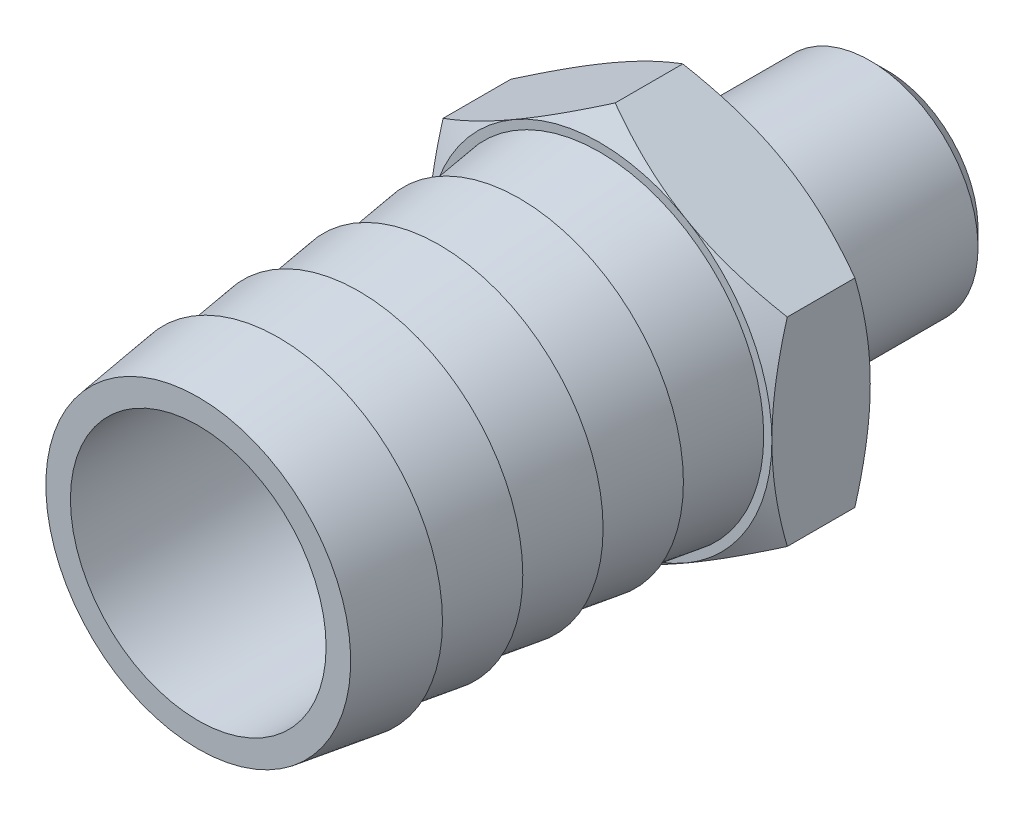
from build123d import *

# Parameters (mm, degrees)
LPATTERN1_COUNT     = 5
LPATTERN1_PITCH     = 4.9
BOSS_EXTRUDE1_START = -9.5
BOSS_EXTRUDE1_DEPTH = 6
SKETCH5_OUTSIDE_W   = 136.756
SKETCH5_OUTSIDE_H   = 140.004
SKETCH5_OUTSIDE_R   = 10.5
CUT_EXTRUDE1_DEPTH  = 30.283100929
CUT_EXTRUDE1_DRAFT  = -60
SKETCH6_OUTSIDE_W   = 154.69
SKETCH6_OUTSIDE_H   = 157.938
SKETCH6_OUTSIDE_R   = 10.5
CUT_EXTRUDE2_DEPTH  = 35.46012188
CUT_EXTRUDE2_DRAFT  = -60
SKETCH12_R          = 1.123521783


with BuildPart() as part:
    # Sketch2 → Revolve2 (revolve)
    with BuildSketch(Plane(origin=(0, 0, 0), x_dir=(0, 0, -1), z_dir=(1, 0, 0)), mode=Mode.PRIVATE) as revolve2_sk:
        Polygon((-21, 9.3), (-16.1, 10), (-16.1, 0), (-21, 0), align=None)
    revolve(revolve2_sk.sketch.rotate(Axis((0, 0, 21), (0, 0, -1)), 180), axis=Axis((0, 0, 21), (0, 0, -1)))


with BuildPart() as lpattern1_1:
    # LPattern1: pattern copy
    add(part.part.moved(Location(Vector(0, 0, -1) * (1 * LPATTERN1_PITCH))))


with BuildPart() as lpattern1_2:
    # LPattern1: pattern copy
    add(part.part.moved(Location(Vector(0, 0, -1) * (2 * LPATTERN1_PITCH))))


with BuildPart() as lpattern1_3:
    # LPattern1: pattern copy
    add(part.part.moved(Location(Vector(0, 0, -1) * (3 * LPATTERN1_PITCH))))


with BuildPart() as lpattern1_4:
    # LPattern1: pattern copy
    add(part.part.moved(Location(Vector(0, 0, -1) * (4 * LPATTERN1_PITCH))))


with BuildPart() as body_6:
    # Sketch3 → Boss-Extrude1 (new body)
    with BuildSketch(Plane.XY.offset(BOSS_EXTRUDE1_START)):
        Polygon((0, 12.124355653), (-10.5, 6.062177826), (-10.5, -6.062177826), (0, -12.124355653), (10.5, -6.062177826), (10.5, 6.062177826), align=None)
    extrude(amount=BOSS_EXTRUDE1_DEPTH)


with BuildPart() as cut_extrude1_tool:
    # Sketch5 outside → Cut-Extrude1 (with draft: the straight prism first)
    with BuildSketch(Plane.XY.offset(-3.5)):
        Rectangle(SKETCH5_OUTSIDE_W, SKETCH5_OUTSIDE_H)
        Circle(SKETCH5_OUTSIDE_R, mode=Mode.SUBTRACT)
    extrude(amount=-CUT_EXTRUDE1_DEPTH)
    # Cut-Extrude1: the draft: its side faces are tilted about the plane it starts from
    cut_extrude1_sides = [cut_extrude1_tool.faces().sort_by_distance(p)[0] for p in [
        (0, -70.002, -18.641550464),
        (68.378, 0, -18.641550464),
        (0, 70.002, -18.641550464),
        (-68.378, 0, -18.641550464),
        (-10.5, 0, -18.641550464),
    ]]
    draft(cut_extrude1_sides, Plane.XY.offset(-3.5), CUT_EXTRUDE1_DRAFT)


with BuildPart() as body_6_1:
    add(body_6.part)

    # Cut-Extrude1: cut by cut_extrude1_tool
    add(cut_extrude1_tool.part, mode=Mode.SUBTRACT)


with BuildPart() as cut_extrude2_tool:
    # Sketch6 outside → Cut-Extrude2 (with draft: the straight prism first)
    with BuildSketch(Plane(origin=(0, 0, -9.5), x_dir=(-1, 0, 0), z_dir=(0, 0, -1))):
        Rectangle(SKETCH6_OUTSIDE_W, SKETCH6_OUTSIDE_H)
        Circle(SKETCH6_OUTSIDE_R, mode=Mode.SUBTRACT)
    extrude(amount=-CUT_EXTRUDE2_DEPTH)
    # Cut-Extrude2: the draft: its side faces are tilted about the plane it starts from
    cut_extrude2_sides = [cut_extrude2_tool.faces().sort_by_distance(p)[0] for p in [
        (0, -78.969, 8.23006094),
        (-77.345, 0, 8.23006094),
        (0, 78.969, 8.23006094),
        (77.345, 0, 8.23006094),
        (10.5, 0, 8.23006094),
    ]]
    draft(cut_extrude2_sides, Plane(origin=(0, 0, -9.5), x_dir=(-1, 0, 0), z_dir=(0, 0, -1)), CUT_EXTRUDE2_DRAFT)


with BuildPart() as body_6_2:
    add(body_6_1.part)

    # Cut-Extrude2: cut by cut_extrude2_tool
    add(cut_extrude2_tool.part, mode=Mode.SUBTRACT)


with BuildPart() as part_1:
    add(part.part)

    add(lpattern1_1.part)  # Revolve1 merges LPattern1_1

    add(lpattern1_2.part)  # Revolve1 merges LPattern1_2

    add(lpattern1_3.part)  # Revolve1 merges LPattern1_3

    add(lpattern1_4.part)  # Revolve1 merges LPattern1_4

    add(body_6_2.part)  # Revolve1 merges body 6
    # Sketch4 → Revolve1 (revolve)
    with BuildSketch(Plane(origin=(0, 0, 0), x_dir=(0, 0, -1), z_dir=(1, 0, 0)), mode=Mode.PRIVATE) as revolve1_sk:
        Polygon((-21, 9.3), (9.5, 9.3), (9.5, 6.5786), (19.997368421, 6.5786), (21, 5.575968421), (21, 0), (-21, 0), align=None)
    revolve(revolve1_sk.sketch.rotate(Axis((0, 0, 21), (0, 0, -1)), 180), axis=Axis((0, 0, 21), (0, 0, -1)))

    # Sketch7 → Cut-Revolve1 (revolve, cut)
    with BuildSketch(Plane(origin=(0, 0, 0), x_dir=(0, 0, -1), z_dir=(1, 0, 0)), mode=Mode.PRIVATE) as cut_revolve1_sk:
        Polygon((-21, 0), (-21, 7.8), (6.5, 7.8), (6.5, 4.60502), (9.5, 4.60502), (21, 4.60502), (21, 0), align=None)
        with BuildLine():
            Line((9.5, 5.455078217), (10.168421053, 5.455078217))
            Line((10.168421053, 5.455078217), (11.372194392, 6.658851556))
            Line((11.372194392, 6.658851556), (10.620651991, 6.658851556))
            ThreePointArc((10.620651991, 6.658851556), (8.677666257, 7.344151052), (9.5, 5.455078217))
        make_face()
    revolve(cut_revolve1_sk.sketch.rotate(Axis((0, 0, 21), (0, 0, -1)), 180), axis=Axis((0, 0, 21), (0, 0, -1)), mode=Mode.SUBTRACT)


with BuildPart() as body_2:
    # Sketch12 → Revolve3 (revolve)
    with BuildSketch(Plane(origin=(0, 0, 0), x_dir=(0, 0, -1), z_dir=(1, 0, 0))):
        with Locations((9.5, 6.5786)):
            Circle(SKETCH12_R)
    revolve(axis=Axis((0, 0, 21), (0, 0, -1)))


solid = Compound([part_1.part, body_2.part])
